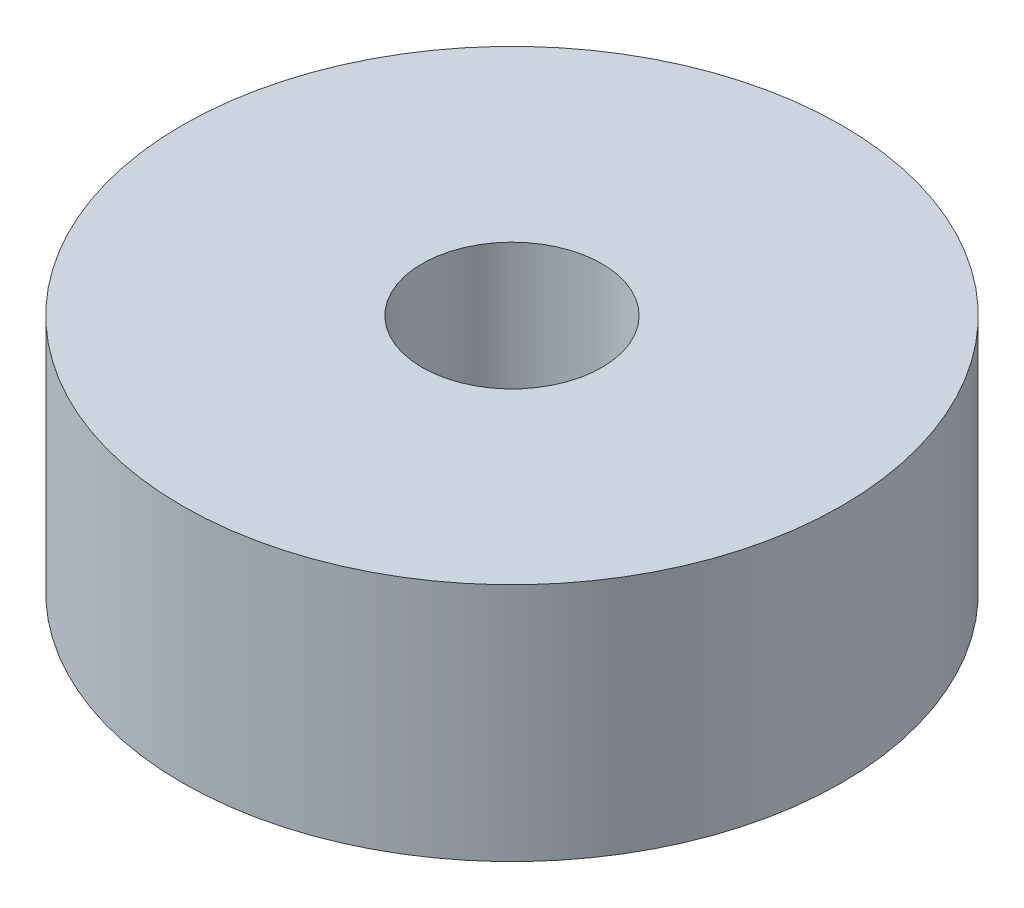
from build123d import *

# Parameters (mm, degrees)
SKETCH1_R           = 5.5
SKETCH1_R_2         = 1.5
BOSS_EXTRUDE1_DEPTH = 4


with BuildPart() as part:
    # Sketch1 → Boss-Extrude1 (new body)
    with BuildSketch(Plane(origin=(0, 0, 0), x_dir=(1, 0, 0), z_dir=(0, 1, 0))):
        Circle(SKETCH1_R)
        Circle(SKETCH1_R_2, mode=Mode.SUBTRACT)
    extrude(amount=BOSS_EXTRUDE1_DEPTH)


solid = part.part
